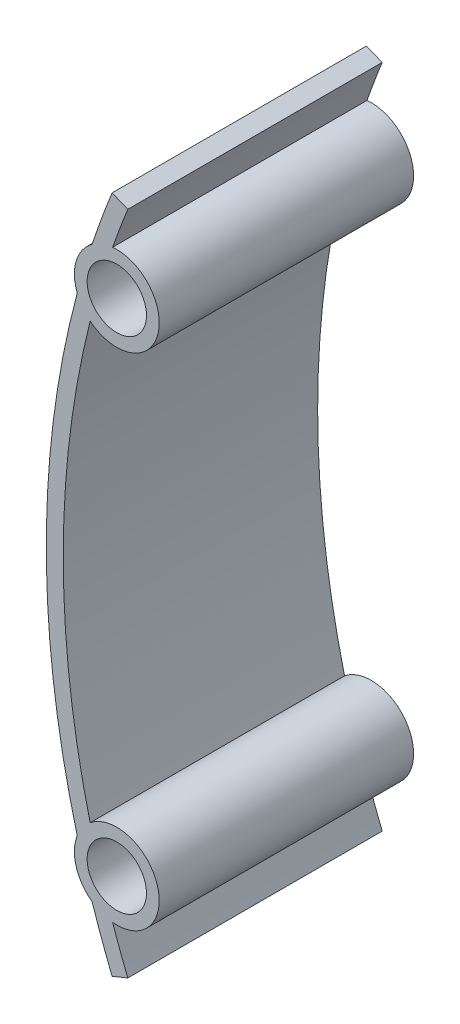
from build123d import *

# Parameters (mm, degrees)
SKETCH1_R           = 3.5
BOSS_EXTRUDE1_DEPTH = 30


with BuildPart() as part:
    # Sketch1 → Boss-Extrude1 (new body)
    with BuildSketch(Plane.XY):
        with BuildLine():
            Line((7.757871849, 40), (9.612864898, 39.252336449))
            ThreePointArc((9.612864898, 39.252336449), (8.688014127, 36.874834695), (7.821195192, 34.475566375))
            ThreePointArc((7.821195192, 34.475566375), (13.105433831, 28.067961165), (5.171505388, 25.611670876))
            ThreePointArc((5.171505388, 25.611670876), (2, 0), (5.171505388, -25.611670876))
            ThreePointArc((5.171505388, -25.611670876), (13.105433831, -28.067961165), (7.821195192, -34.475566375))
            ThreePointArc((7.821195192, -34.475566375), (8.688014127, -36.874834695), (9.612864898, -39.252336449))
            Line((9.612864898, -39.252336449), (7.757871849, -40))
            ThreePointArc((7.757871849, -40), (6.527354129, -36.800100973), (5.399981488, -33.562423012))
            ThreePointArc((5.399981488, -33.562423012), (3.524355651, -30.932038835), (3.648663608, -27.703813202))
            ThreePointArc((3.648663608, -27.703813202), (0, 0), (3.648663608, 27.703813202))
            ThreePointArc((3.648663608, 27.703813202), (3.524355651, 30.932038835), (5.399981488, 33.562423012))
            ThreePointArc((5.399981488, 33.562423012), (6.527354129, 36.800100973), (7.757871849, 40))
        make_face()
        with Locations((8.314894741, 29.5)):
            Circle(SKETCH1_R, mode=Mode.SUBTRACT)
        with Locations((8.314894741, -29.5)):
            Circle(SKETCH1_R, mode=Mode.SUBTRACT)
    extrude(amount=BOSS_EXTRUDE1_DEPTH)


solid = part.part
